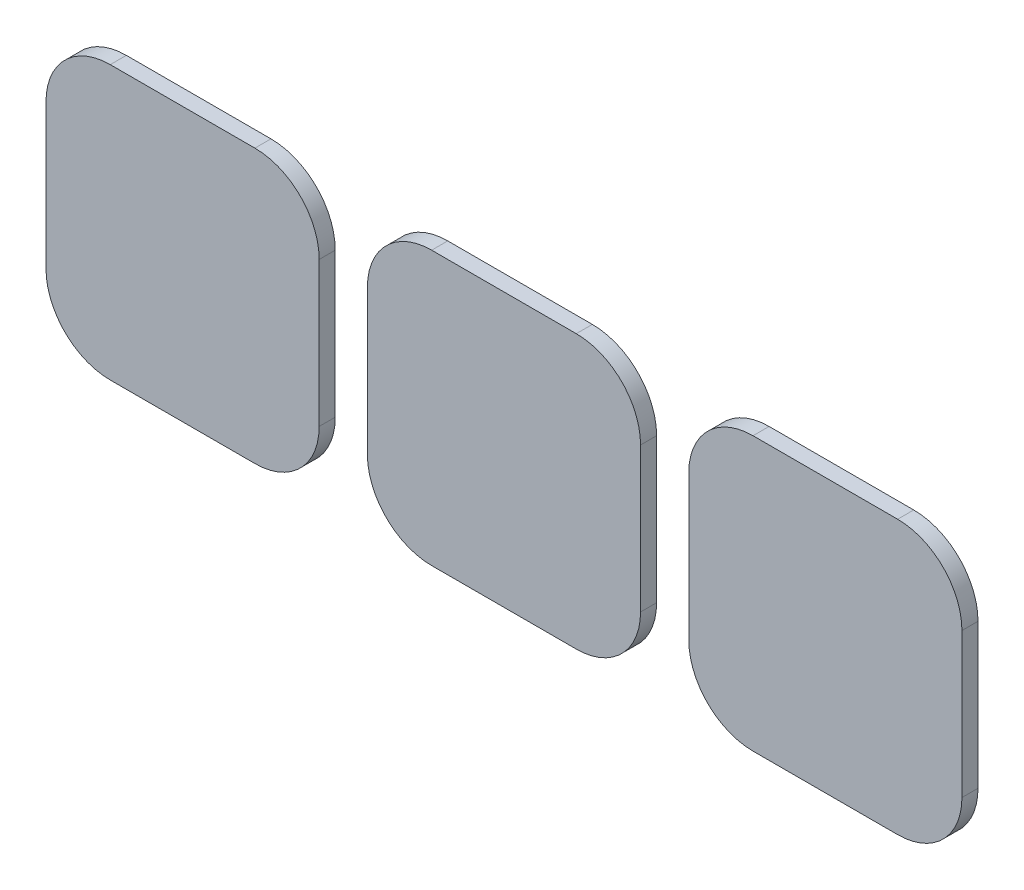
from build123d import *

# Parameters (mm, degrees)
SKICA1_W                 = 7
SKICA1_H                 = 5.5
P_IDAT_VYSUNUT_M1_DEPTH  = 3.6
SKICA2_W                 = 17
SKICA2_H                 = 17
P_IDAT_VYSUNUT_M2_DEPTH  = 1
ZAOBLIT1_R               = 4
LINPOLE1_COUNT           = 3
LINPOLE1_PITCH           = 20
ODEBRAT_VYSUNUT_M1_DEPTH = 3.6


with BuildPart() as part:
    # Skica1 → Přidat vysunutím1 (new body)
    with BuildSketch(Plane.XY):
        Rectangle(SKICA1_W, SKICA1_H)
        Polygon((-0.7, 0.7), (-0.7, 2.25), (0.7, 2.25), (0.7, 0.7), (2.25, 0.7), (2.25, -0.7), (0.7, -0.7), (0.7, -2.25), (-0.7, -2.25), (-0.7, -0.7), (-2.25, -0.7), (-2.25, 0.7), align=None, mode=Mode.SUBTRACT)
    extrude(amount=P_IDAT_VYSUNUT_M1_DEPTH)

    # Skica2 → Přidat vysunutím2 (add)
    with BuildSketch(Plane.XY.offset(3.6)):
        Rectangle(SKICA2_W, SKICA2_H)
    extrude(amount=P_IDAT_VYSUNUT_M2_DEPTH)

    # Zaoblit1
    zaoblit1_edges = [part.edges().sort_by_distance(p)[0] for p in [
        (8.5, -8.5, 4.1),
        (8.5, 8.5, 4.1),
        (-8.5, 8.5, 4.1),
        (-8.5, -8.5, 4.1),
    ]]
    fillet(zaoblit1_edges, radius=ZAOBLIT1_R)


with BuildPart() as linpole1_1:
    # LinPole1: pattern copy
    add(part.part.moved(Location(Vector(-1, 0, 0) * (1 * LINPOLE1_PITCH))))


with BuildPart() as linpole1_2:
    # LinPole1: pattern copy
    add(part.part.moved(Location(Vector(-1, 0, 0) * (2 * LINPOLE1_PITCH))))


with BuildPart() as odebrat_vysunut_m1_tool:
    # Skica4 → Odebrat vysunutím1 (new body)
    with BuildSketch(Plane(origin=(0, 0, 0), x_dir=(-1, 0, 0), z_dir=(0, 0, -1))):
        Polygon((19.25, 2.3), (19.25, 0.75), (17.7, 0.75), (17.7, -0.75), (19.25, -0.75), (19.25, -2.3), (20.75, -2.3), (20.75, -0.75), (22.3, -0.75), (22.3, 0.75), (20.75, 0.75), (20.75, 2.3), align=None)
        Polygon((39.2, 2.35), (39.2, 0.8), (37.65, 0.8), (37.65, -0.8), (39.2, -0.8), (39.2, -2.35), (40.8, -2.35), (40.8, -0.8), (42.35, -0.8), (42.35, 0.8), (40.8, 0.8), (40.8, 2.35), align=None)
    extrude(amount=-ODEBRAT_VYSUNUT_M1_DEPTH)


with BuildPart() as linpole1_1_1:
    add(linpole1_1.part)

    # Odebrat vysunutím1: cut by odebrat_vysunut_m1_tool
    add(odebrat_vysunut_m1_tool.part, mode=Mode.SUBTRACT)


with BuildPart() as linpole1_2_1:
    add(linpole1_2.part)

    # Odebrat vysunutím1: cut by odebrat_vysunut_m1_tool
    add(odebrat_vysunut_m1_tool.part, mode=Mode.SUBTRACT)


solid = Compound([part.part, linpole1_1_1.part, linpole1_2_1.part])
